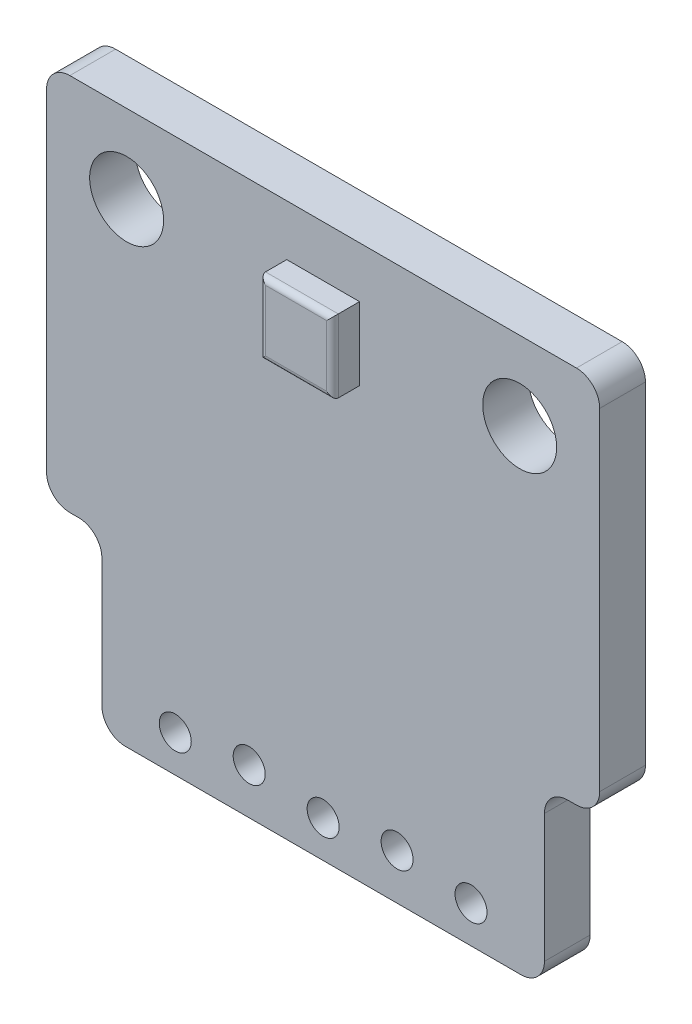
from build123d import *

# Parameters (mm, degrees)
SKETCH1_R           = 1.27
SKETCH1_R_2         = 0.55
BOSS_EXTRUDE1_DEPTH = 1.57
FILLET1_R           = 0.8
SKETCH2_W           = 2.5
SKETCH2_H           = 2.5
BOSS_EXTRUDE2_DEPTH = 0.93
FILLET2_R           = 0.2


with BuildPart() as part:
    # Sketch1 → Boss-Extrude1 (new body)
    with BuildSketch(Plane.XY):
        Polygon((-9.5, 19), (-9.5, 6), (-7.6, 6), (-7.6, 0), (7.6, 0), (7.6, 6), (9.5, 6), (9.5, 19), align=None)
        with Locations((-6.75, 16.3)):
            Circle(SKETCH1_R, mode=Mode.SUBTRACT)
        with Locations((6.75, 16.3)):
            Circle(SKETCH1_R, mode=Mode.SUBTRACT)
        with Locations((0, 1.27)):
            Circle(SKETCH1_R_2, mode=Mode.SUBTRACT)
        with Locations((-5.08, 1.27)):
            Circle(SKETCH1_R_2, mode=Mode.SUBTRACT)
        with Locations((5.08, 1.27)):
            Circle(SKETCH1_R_2, mode=Mode.SUBTRACT)
        with Locations((-2.54, 1.57)):
            Circle(SKETCH1_R_2, mode=Mode.SUBTRACT)
        with Locations((2.54, 1.57)):
            Circle(SKETCH1_R_2, mode=Mode.SUBTRACT)
    extrude(amount=BOSS_EXTRUDE1_DEPTH)

    # Fillet1
    fillet1_edges = [part.edges().sort_by_distance(p)[0] for p in [
        (9.5, 6, 0.785),
        (7.6, 6, 0.785),
        (7.6, 0, 0.785),
        (-7.6, 0, 0.785),
        (-7.6, 6, 0.785),
        (-9.5, 6, 0.785),
        (-9.5, 19, 0.785),
        (9.5, 19, 0.785),
    ]]
    fillet(fillet1_edges, radius=FILLET1_R)

    # Sketch2 → Boss-Extrude2 (add)
    with BuildSketch(Plane.XY.offset(1.57)):
        with Locations((0, 16)):
            Rectangle(SKETCH2_W, SKETCH2_H)
    extrude(amount=BOSS_EXTRUDE2_DEPTH)

    # Fillet2
    fillet2_edges = [part.edges().sort_by_distance(p)[0] for p in [
        (1.25, 16, 2.5),
        (0, 17.25, 2.5),
        (-1.25, 16, 2.5),
        (0, 14.75, 2.5),
    ]]
    fillet(fillet2_edges, radius=FILLET2_R)


solid = part.part
